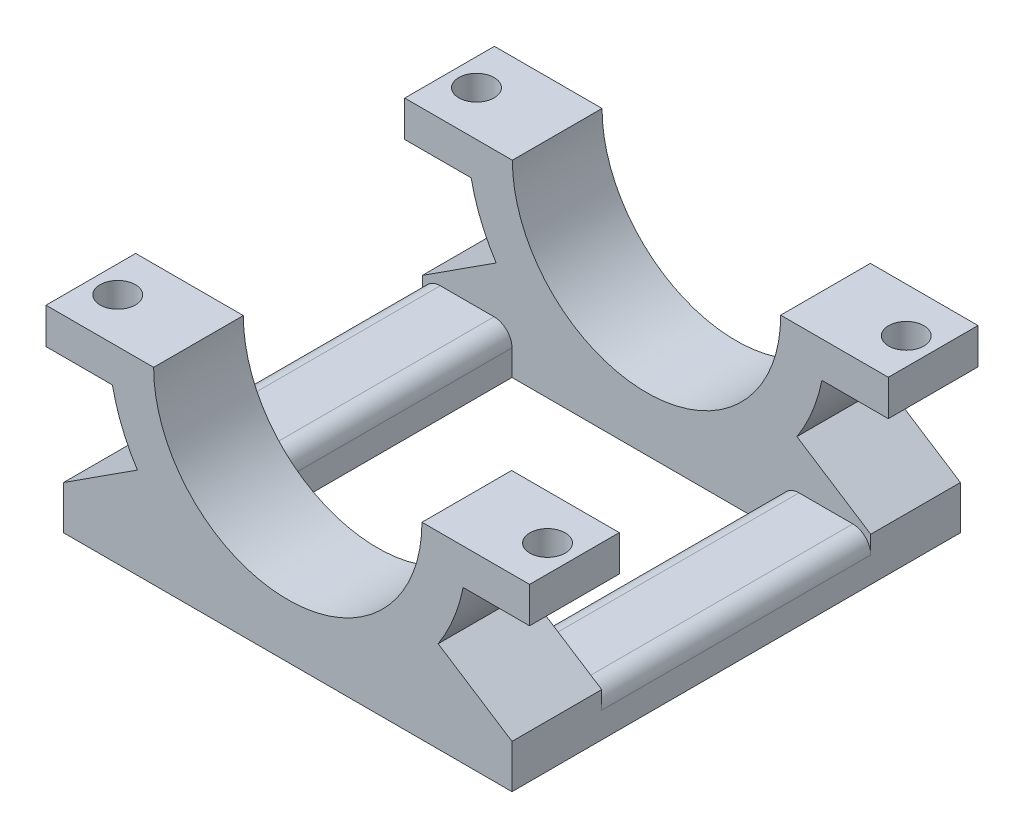
from build123d import *

# Parameters (mm, degrees)
BOSS_EXTRUDE1_DEPTH           = 12.7
SKETCH3_R                     = 3.81
BOSS_EXTRUDE2_DEPTH           = 2.54
BOSS_EXTRUDE2_DRAFT           = 5
BOSS_EXTRUDE2_PROFILE_2_DEPTH = 2.54
BOSS_EXTRUDE2_PROFILE_2_DRAFT = 5
BOSS_EXTRUDE3_START           = -38.1
BOSS_EXTRUDE3_DEPTH           = 12.7
SKETCH6_R                     = 3.81
BOSS_EXTRUDE4_DEPTH           = 2.54
BOSS_EXTRUDE4_DRAFT           = 5
BOSS_EXTRUDE4_PROFILE_2_DEPTH = 2.54
BOSS_EXTRUDE4_PROFILE_2_DRAFT = 5
BOSS_EXTRUDE5_REACH           = 78.769
SKETCH7_W                     = 12.7
SKETCH7_H                     = 6.172188314
SKETCH8_W                     = 15.24
SKETCH8_H                     = 12.7
BOSS_EXTRUDE6_DEPTH           = 5.08
SKETCH9_R                     = 2.5
CUT_EXTRUDE3_DEPTH            = 5.08
FILLET6_R                     = 2.54


with BuildPart() as part:
    # Sketch2 → Boss-Extrude1 (new body)
    with BuildSketch(Plane.XY):
        with BuildLine():
            Line((-31.75, -26.67), (31.75, -26.67))
            Line((31.75, -26.67), (31.75, -20.497811686))
            Line((31.75, -20.497811686), (21.297259116, -13.749518324))
            ThreePointArc((21.297259116, -13.749518324), (24.315715274, -7.167181503), (25.35, 0))
            Line((25.35, 0), (19, 0))
            ThreePointArc((19, 0), (0, -19), (-19, 0))
            Line((-19, 0), (-25.35, 0))
            ThreePointArc((-25.35, 0), (-24.315715274, -7.167181503), (-21.297259116, -13.749518324))
            Line((-21.297259116, -13.749518324), (-31.75, -20.497811686))
            Line((-31.75, -20.497811686), (-31.75, -26.67))
        make_face()
    extrude(amount=BOSS_EXTRUDE1_DEPTH)


with BuildPart() as boss_extrude2_tool:
    # Sketch3 → Boss-Extrude2 (with draft: the straight prism first)
    with BuildSketch(Plane.XZ.offset(26.67)):
        with Locations((-25.4, 6.35)):
            Circle(SKETCH3_R)
    extrude(amount=BOSS_EXTRUDE2_DEPTH)
    # Boss-Extrude2: the draft: its side faces are tilted about the plane it starts from
    boss_extrude2_sides = [boss_extrude2_tool.faces().sort_by_distance(p)[0] for p in [
        (-29.21, -27.94, 6.35),
    ]]
    draft(boss_extrude2_sides, Plane.XZ.offset(26.67), BOSS_EXTRUDE2_DRAFT)


with BuildPart() as part_1:
    add(part.part)

    # Boss-Extrude2: add boss_extrude2_tool
    add(boss_extrude2_tool.part)


with BuildPart() as boss_extrude2_profile_2_tool:
    # Sketch3 → Boss-Extrude2 profile 2 (with draft: the straight prism first)
    with BuildSketch(Plane.XZ.offset(26.67)):
        with Locations((25.4, 6.35)):
            Circle(SKETCH3_R)
    extrude(amount=BOSS_EXTRUDE2_PROFILE_2_DEPTH)
    # Boss-Extrude2 profile 2: the draft: its side faces are tilted about the plane it starts from
    boss_extrude2_profile_2_sides = [boss_extrude2_profile_2_tool.faces().sort_by_distance(p)[0] for p in [
        (21.59, -27.94, 6.35),
    ]]
    draft(boss_extrude2_profile_2_sides, Plane.XZ.offset(26.67), BOSS_EXTRUDE2_PROFILE_2_DRAFT)


with BuildPart() as part_2:
    add(part_1.part)

    # Boss-Extrude2 profile 2: add boss_extrude2_profile_2_tool
    add(boss_extrude2_profile_2_tool.part)


with BuildPart() as body_2:
    # Sketch2_2 → Boss-Extrude3 (new body)
    with BuildSketch(Plane.XY.offset(BOSS_EXTRUDE3_START)):
        with BuildLine():
            Line((-31.75, -26.67), (31.75, -26.67))
            Line((31.75, -26.67), (31.75, -20.497811686))
            Line((31.75, -20.497811686), (21.297259116, -13.749518324))
            ThreePointArc((21.297259116, -13.749518324), (24.315715274, -7.167181503), (25.35, 0))
            Line((25.35, 0), (19, 0))
            ThreePointArc((19, 0), (0, -19), (-19, 0))
            Line((-19, 0), (-25.35, 0))
            ThreePointArc((-25.35, 0), (-24.315715274, -7.167181503), (-21.297259116, -13.749518324))
            Line((-21.297259116, -13.749518324), (-31.75, -20.497811686))
            Line((-31.75, -20.497811686), (-31.75, -26.67))
        make_face()
    extrude(amount=-BOSS_EXTRUDE3_DEPTH)


with BuildPart() as boss_extrude4_tool:
    # Sketch6 → Boss-Extrude4 (with draft: the straight prism first)
    with BuildSketch(Plane.XZ.offset(26.67)):
        with Locations((-25.4, -44.45)):
            Circle(SKETCH6_R)
    extrude(amount=BOSS_EXTRUDE4_DEPTH)
    # Boss-Extrude4: the draft: its side faces are tilted about the plane it starts from
    boss_extrude4_sides = [boss_extrude4_tool.faces().sort_by_distance(p)[0] for p in [
        (-29.21, -27.94, -44.45),
    ]]
    draft(boss_extrude4_sides, Plane.XZ.offset(26.67), BOSS_EXTRUDE4_DRAFT)


with BuildPart() as body_2_1:
    add(body_2.part)

    # Boss-Extrude4: add boss_extrude4_tool
    add(boss_extrude4_tool.part)


with BuildPart() as boss_extrude4_profile_2_tool:
    # Sketch6 → Boss-Extrude4 profile 2 (with draft: the straight prism first)
    with BuildSketch(Plane.XZ.offset(26.67)):
        with Locations((25.4, -44.45)):
            Circle(SKETCH6_R)
    extrude(amount=BOSS_EXTRUDE4_PROFILE_2_DEPTH)
    # Boss-Extrude4 profile 2: the draft: its side faces are tilted about the plane it starts from
    boss_extrude4_profile_2_sides = [boss_extrude4_profile_2_tool.faces().sort_by_distance(p)[0] for p in [
        (21.59, -27.94, -44.45),
    ]]
    draft(boss_extrude4_profile_2_sides, Plane.XZ.offset(26.67), BOSS_EXTRUDE4_PROFILE_2_DRAFT)


with BuildPart() as body_2_2:
    add(body_2_1.part)

    # Boss-Extrude4 profile 2: add boss_extrude4_profile_2_tool
    add(boss_extrude4_profile_2_tool.part)

    # Sketch7 → Boss-Extrude5 (add, up to next)
    with BuildSketch(Plane.XY.offset(12.7), mode=Mode.PRIVATE) as boss_extrude5_sk1:
        with Locations((-25.4, -23.583905843)):
            Rectangle(SKETCH7_W, SKETCH7_H)
    boss_extrude5_tool1 = extrude(boss_extrude5_sk1.sketch, amount=-BOSS_EXTRUDE5_REACH, mode=Mode.PRIVATE) - body_2_2.part
    # Sketch7 → Boss-Extrude5 (add, up to next)
    with BuildSketch(Plane.XY.offset(12.7), mode=Mode.PRIVATE) as boss_extrude5_sk2:
        with Locations((25.4, -23.583905843)):
            Rectangle(SKETCH7_W, SKETCH7_H)
    boss_extrude5_tool2 = extrude(boss_extrude5_sk2.sketch, amount=-BOSS_EXTRUDE5_REACH, mode=Mode.PRIVATE) - body_2_2.part

    add(part_2.part)  # Boss-Extrude5 merges part
    add(boss_extrude5_tool1.solids().sort_by_distance((-25.4, -23.583906, 12.7))[0])
    add(boss_extrude5_tool2.solids().sort_by_distance((25.4, -23.583906, 12.7))[0])

    # Sketch8 → Boss-Extrude6 (add)
    with BuildSketch(Plane(origin=(0, 0, 0), x_dir=(1, 0, 0), z_dir=(0, 1, 0))):
        with Locations((26.62, -6.35)):
            Rectangle(SKETCH8_W, SKETCH8_H)
        with Locations((-26.62, 44.45)):
            Rectangle(SKETCH8_W, SKETCH8_H)
        with Locations((26.62, 44.45)):
            Rectangle(SKETCH8_W, SKETCH8_H)
        with Locations((-26.62, -6.35)):
            Rectangle(SKETCH8_W, SKETCH8_H)
    extrude(amount=-BOSS_EXTRUDE6_DEPTH)

    # Sketch9 → Cut-Extrude3 (cut)
    with BuildSketch(Plane(origin=(0, -5.08, 0), x_dir=(-1, 0, 0), z_dir=(0, -1, 0))):
        with Locations((30.43, 44.45)):
            Circle(SKETCH9_R)
        with Locations((-30.43, 44.45)):
            Circle(SKETCH9_R)
        with Locations((-30.43, -6.35)):
            Circle(SKETCH9_R)
        with Locations((30.43, -6.35)):
            Circle(SKETCH9_R)
    extrude(amount=-CUT_EXTRUDE3_DEPTH, mode=Mode.SUBTRACT)

    # Fillet6
    fillet6_edges = [body_2_2.edges().sort_by_distance(p)[0] for p in [
        (31.75, -20.497811686, -19.05),
        (19.05, -20.497811686, -19.05),
        (-19.05, -20.497811686, -19.05),
        (-31.75, -20.497811686, -19.05),
    ]]
    fillet(fillet6_edges, radius=FILLET6_R)


solid = body_2_2.part
